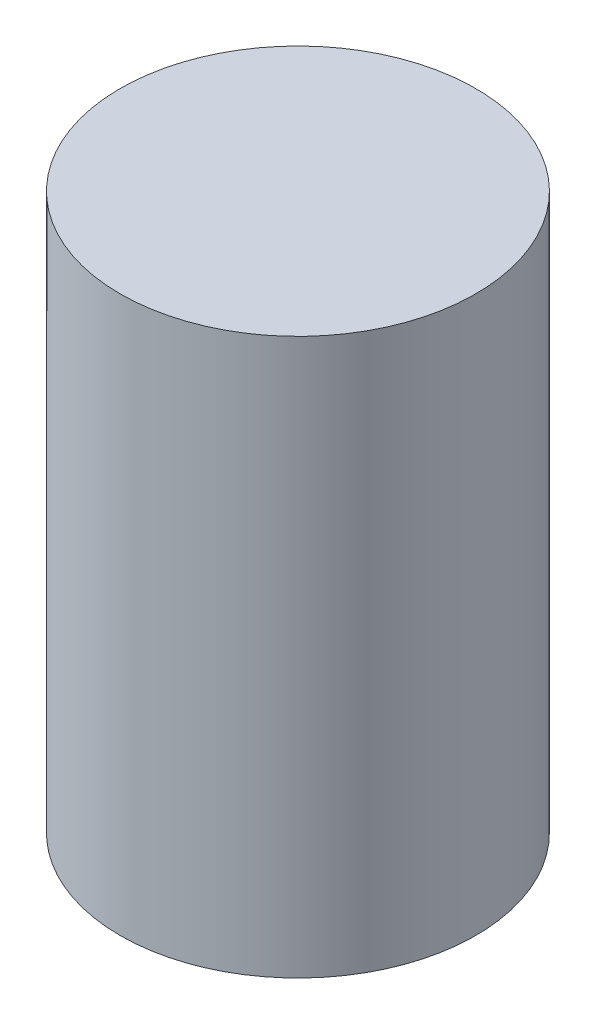
from build123d import *

# Parameters (mm, degrees)
SKETCH1_R           = 4.8
BOSS_EXTRUDE1_DEPTH = 15
CUT_EXTRUDE1_DEPTH  = 1


with BuildPart() as part:
    # Sketch1 → Boss-Extrude1 (new body)
    with BuildSketch(Plane(origin=(0, 0, 0), x_dir=(1, 0, 0), z_dir=(0, 1, 0))):
        with Locations(Location((0, 0, 0), (0, 0, 270))):  # turned: the seam where the file's is
            Circle(SKETCH1_R)
    extrude(amount=BOSS_EXTRUDE1_DEPTH)

    # Sketch2 → Cut-Extrude1 (cut, symmetric)
    with BuildSketch(Plane(origin=(0, 0, 0), x_dir=(0, 0, -1), z_dir=(1, 0, 0))):
        Polygon((-2.5, 0), (2.5, 0), (2.5, 4), (2, 4), (2, 8), (-2, 8), (-2, 4), (-2.5, 4), align=None)
    extrude(amount=CUT_EXTRUDE1_DEPTH, both=True, mode=Mode.SUBTRACT)


solid = part.part
